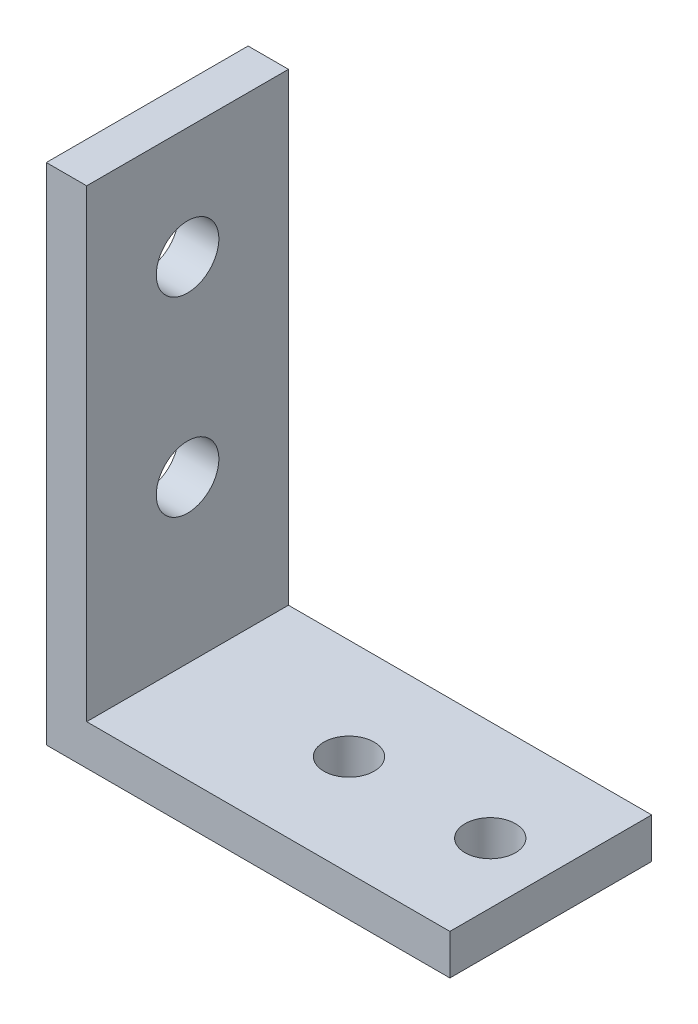
from build123d import *

# Parameters (mm, degrees)
BASE_DEPTH                   = 5
M3X0_5_MOUNTHOLES_D          = 2.5
F_3_1_3_1_LIMITSWITCHHOLES_D = 3.1


with BuildPart() as part:
    # Sketch1 → Base (new body, symmetric)
    with BuildSketch(Plane.XY):
        Polygon((0, 0), (0, 25), (2, 25), (2, 2), (20, 2), (20, 0), align=None)
    extrude(amount=BASE_DEPTH, both=True)

    # M3x0.5 MountHoles (through all)
    with Locations(Plane(origin=(0, 0, 0), x_dir=(-1, 0, 0), z_dir=(0, -1, 0))):
        with Locations((-10, 0), (-17, 0)):
            Hole(M3X0_5_MOUNTHOLES_D / 2)

    # Ø3.1 (3.1) LimitSwitchHoles (through all)
    with Locations(Plane(origin=(0, 10, 0), x_dir=(0, 0, -1), z_dir=(-1, 0, 0))):
        with Locations((0, 0), (0, -9.45)):
            Hole(F_3_1_3_1_LIMITSWITCHHOLES_D / 2)


solid = part.part
